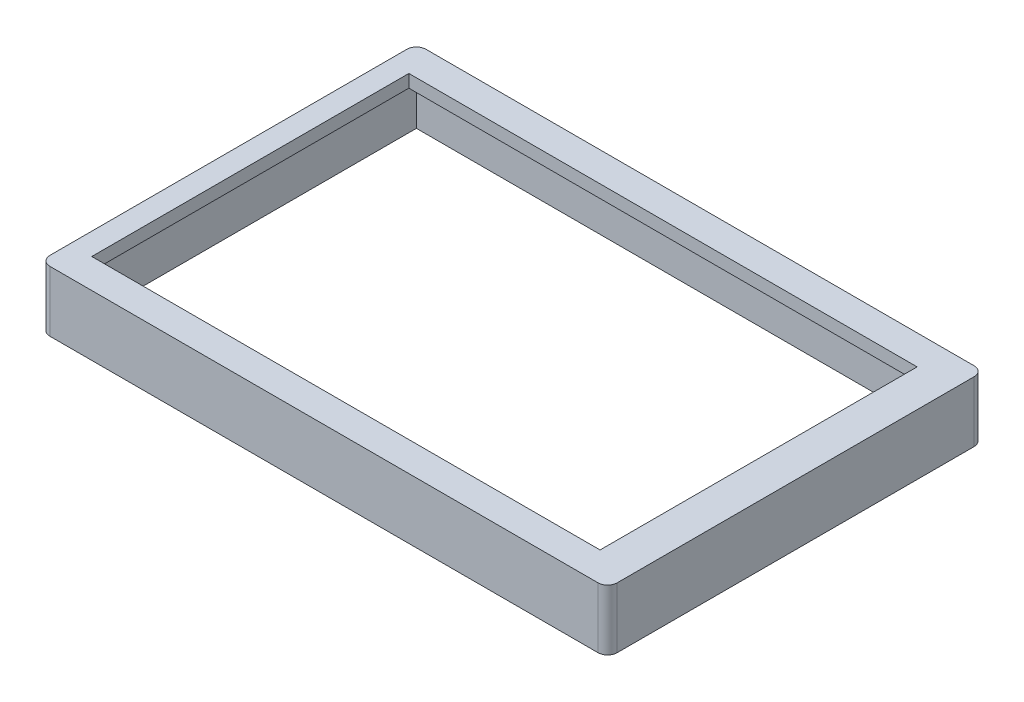
from build123d import *

# Parameters (mm, degrees)
SKETCH1_W           = 178
SKETCH1_H           = 118
SKETCH1_W_2         = 159.5
SKETCH1_H_2         = 99.5
BOSS_EXTRUDE1_DEPTH = 4
SKETCH2_W           = 178
SKETCH2_H           = 118
SKETCH2_W_2         = 170
SKETCH2_H_2         = 110
BOSS_EXTRUDE2_DEPTH = 15
FILLET1_R           = 3


with BuildPart() as part:
    # Sketch1 → Boss-Extrude1 (new body)
    with BuildSketch(Plane(origin=(0, 0, 0), x_dir=(1, 0, 0), z_dir=(0, 1, 0))):
        with Locations((2.365202132, 0)):
            Rectangle(SKETCH1_W, SKETCH1_H)
        Rectangle(SKETCH1_W_2, SKETCH1_H_2, mode=Mode.SUBTRACT)
    extrude(amount=BOSS_EXTRUDE1_DEPTH)

    # Sketch2 → Boss-Extrude2 (add)
    with BuildSketch(Plane.XZ):
        with Locations((2.365202132, 0)):
            Rectangle(SKETCH2_W, SKETCH2_H)
        with Locations((2.365202132, 0)):
            Rectangle(SKETCH2_W_2, SKETCH2_H_2, mode=Mode.SUBTRACT)
    extrude(amount=BOSS_EXTRUDE2_DEPTH)

    # Fillet1
    fillet1_edges = [part.edges().sort_by_distance(p)[0] for p in [
        (-86.634797868, -5.5, -59),
        (91.365202132, -5.5, -59),
        (91.365202132, -5.5, 59),
        (-86.634797868, -5.5, 59),
    ]]
    fillet(fillet1_edges, radius=FILLET1_R)


solid = part.part
